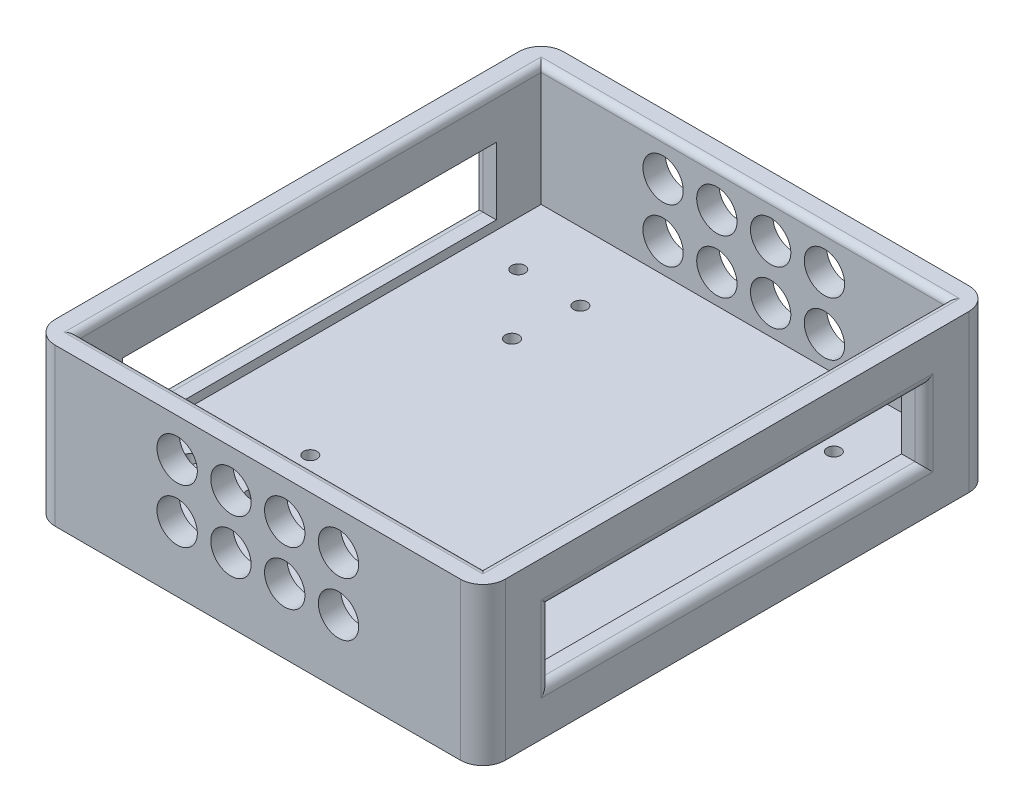
from build123d import *

# Parameters (mm, degrees)
SKETCH1_W            = 100.4
SKETCH1_H            = 113.4
BOSS_EXTRUDE2_DEPTH  = 35
SKETCH2_W            = 90.4
SKETCH2_H            = 103.4
CUT_EXTRUDE1_DEPTH   = 27
FILLET4_R            = 5
SKETCH4_W            = 83.4
SKETCH4_H            = 15
CUT_EXTRUDE3_DEPTH   = 123
FILLET5_R            = 2
FILLET6_R            = 2
SKETCH3_R            = 4.5
CUT_EXTRUDE4_DEPTH   = 123
SKETCH5_R            = 1.5
CUT_EXTRUDE5_DEPTH   = 37
SKETCH6_R            = 3
CUT_EXTRUDE6_DEPTH   = 4
SKETCH7_R            = 1.5
CUT_EXTRUDE7_DEPTH   = 17
SKETCH8_R            = 1.5
CUT_EXTRUDE8_DEPTH   = 9
SKETCH9_R            = 3
CUT_EXTRUDE9_DEPTH   = 4
LPATTERN2_COUNT      = 4
LPATTERN2_PITCH      = 12
LPATTERN2_COUNT_DIR2 = 2
LPATTERN2_PITCH_DIR2 = 12
FILLET7_R            = 1.5


with BuildPart() as part:
    # Sketch1 → Boss-Extrude2 (new body)
    with BuildSketch(Plane(origin=(0, 0, 0), x_dir=(1, 0, 0), z_dir=(0, 1, 0))):
        Rectangle(SKETCH1_W, SKETCH1_H)
    extrude(amount=BOSS_EXTRUDE2_DEPTH)

    # Sketch2 → Cut-Extrude1 (cut)
    with BuildSketch(Plane(origin=(0, 35, 0), x_dir=(1, 0, 0), z_dir=(0, 1, 0))):
        Rectangle(SKETCH2_W, SKETCH2_H)
    extrude(amount=-CUT_EXTRUDE1_DEPTH, mode=Mode.SUBTRACT)

    # Fillet4
    fillet4_edges = [part.edges().sort_by_distance(p)[0] for p in [
        (-50.2, 17.5, 56.7),
        (50.2, 17.5, 56.7),
        (50.2, 17.5, -56.7),
        (-50.2, 17.5, -56.7),
    ]]
    fillet(fillet4_edges, radius=FILLET4_R)

    # Sketch4 → Cut-Extrude3 (cut)
    with BuildSketch(Plane(origin=(50.2, 0, 0), x_dir=(0, 0, -1), z_dir=(1, 0, 0))):
        with Locations((0, 17.5)):
            Rectangle(SKETCH4_W, SKETCH4_H)
    extrude(amount=-CUT_EXTRUDE3_DEPTH, mode=Mode.SUBTRACT)

    # Fillet5
    fillet5_edges = [part.edges().sort_by_distance(p)[0] for p in [
        (50.2, 17.5, 41.7),
        (50.2, 10, 0),
        (50.2, 17.5, -41.7),
        (50.2, 25, 0),
    ]]
    fillet(fillet5_edges, radius=FILLET5_R)

    # Fillet6
    fillet6_edges = [part.edges().sort_by_distance(p)[0] for p in [
        (-50.2, 17.5, 41.7),
        (-50.2, 25, 0),
        (-50.2, 17.5, -41.7),
        (-50.2, 10, 0),
    ]]
    fillet(fillet6_edges, radius=FILLET6_R)

    # Sketch3 → Cut-Extrude4 (cut)
    with BuildSketch(Plane(origin=(0, 0, -56.7), x_dir=(-1, 0, 0), z_dir=(0, 0, -1))):
        with Locations((-18, 14.5)):
            Circle(SKETCH3_R)
    cut_extrude4 = extrude(amount=-CUT_EXTRUDE4_DEPTH, mode=Mode.SUBTRACT)

    # Sketch5 → Cut-Extrude5 (cut)
    with BuildSketch(Plane(origin=(0, 8, 0), x_dir=(1, 0, 0), z_dir=(0, 1, 0))):
        with Locations((-22.5, 22.5)):
            Circle(SKETCH5_R)
        with Locations((22.5, 22.5)):
            Circle(SKETCH5_R)
        with Locations((-22.5, -22.5)):
            Circle(SKETCH5_R)
        with Locations((22.5, -22.5)):
            Circle(SKETCH5_R)
    extrude(amount=-CUT_EXTRUDE5_DEPTH, mode=Mode.SUBTRACT)

    # Sketch6 → Cut-Extrude6 (cut)
    with BuildSketch(Plane.XZ):
        with Locations((-22.5, 22.5)):
            Circle(SKETCH6_R)
        with Locations((-22.5, -22.5)):
            Circle(SKETCH6_R)
        with Locations((22.5, 22.5)):
            Circle(SKETCH6_R)
        with Locations((22.5, -22.5)):
            Circle(SKETCH6_R)
    extrude(amount=-CUT_EXTRUDE6_DEPTH, mode=Mode.SUBTRACT)

    # Sketch7 → Cut-Extrude7 (cut)
    with BuildSketch(Plane.XZ):
        with Locations((-21.25, 36.5)):
            Circle(SKETCH7_R)
        with Locations((-21.25, -36.5)):
            Circle(SKETCH7_R)
        with Locations((21.25, -36.5)):
            Circle(SKETCH7_R)
        with Locations((21.25, 36.5)):
            Circle(SKETCH7_R)
    extrude(amount=-CUT_EXTRUDE7_DEPTH, mode=Mode.SUBTRACT)

    # Sketch8 → Cut-Extrude8 (cut)
    with BuildSketch(Plane(origin=(0, 8, 0), x_dir=(1, 0, 0), z_dir=(0, 1, 0))):
        with Locations((-35.2, 36.6)):
            Circle(SKETCH8_R)
        with Locations((35.2, 36.6)):
            Circle(SKETCH8_R)
        with Locations((-35.2, -36.7)):
            Circle(SKETCH8_R)
        with Locations((35.2, -36.7)):
            Circle(SKETCH8_R)
    extrude(amount=-CUT_EXTRUDE8_DEPTH, mode=Mode.SUBTRACT)

    # Sketch9 → Cut-Extrude9 (cut)
    with BuildSketch(Plane.XZ):
        with Locations((-35.2, 36.7)):
            Circle(SKETCH9_R)
        with Locations((35.2, 36.7)):
            Circle(SKETCH9_R)
        with Locations((-35.2, -36.6)):
            Circle(SKETCH9_R)
        with Locations((35.2, -36.6)):
            Circle(SKETCH9_R)
    extrude(amount=-CUT_EXTRUDE9_DEPTH, mode=Mode.SUBTRACT)

    # LPattern2: Cut-Extrude4 4 × 2
    with Locations(*[(-i * LPATTERN2_PITCH, j * LPATTERN2_PITCH_DIR2, 0) for i in range(LPATTERN2_COUNT) for j in range(LPATTERN2_COUNT_DIR2) if (i, j) != (0, 0)]):
        add(cut_extrude4, mode=Mode.SUBTRACT)

    # Fillet7
    fillet7_edges = [part.edges().sort_by_distance(p)[0] for p in [
        (45.2, 35, 0),
        (0, 35, -51.7),
        (-45.2, 35, 0),
        (0, 35, 51.7),
    ]]
    fillet(fillet7_edges, radius=FILLET7_R)


solid = part.part
